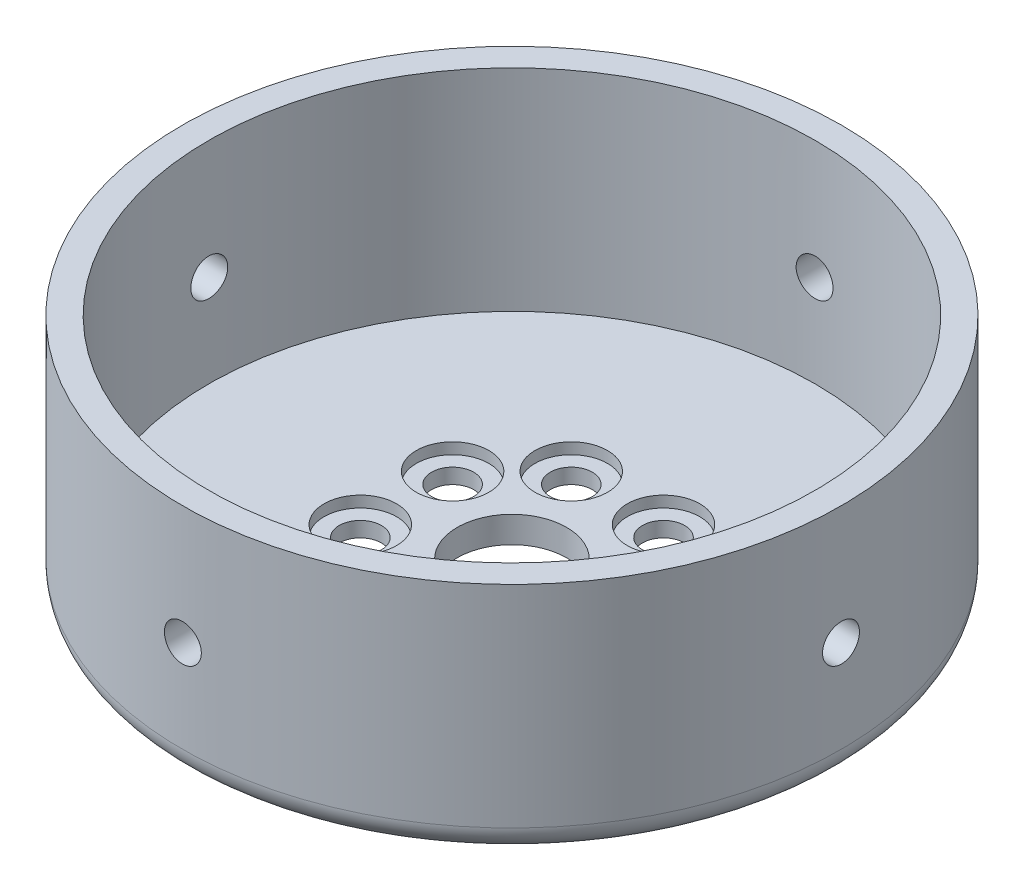
from build123d import *

# Parameters (mm, degrees)
SKETCH2_R          = 4.15
CUT_EXTRUDE1_DEPTH = 10
SKETCH3_R          = 1.4
CUT_EXTRUDE3_DEPTH = 30
CIRPATTERN1_COUNT  = 4
FILLET1_R          = 2
SKETCH4_R          = 1.6
CUT_EXTRUDE4_DEPTH = 19.0000001
SKETCH6_R          = 2.75
CUT_EXTRUDE5_DEPTH = 0.85


with BuildPart() as part:
    # Sketch1 → Revolve1 (revolve)
    with BuildSketch(Plane.XY):
        Polygon((0, 0), (0, 2), (23, 2), (23, 18), (25, 18), (25, 0), align=None)
    revolve(axis=Axis((0, 0, 0), (0, 1, 0)))

    # Sketch2 → Cut-Extrude1 (cut)
    with BuildSketch(Plane(origin=(0, 2, 0), x_dir=(1, 0, 0), z_dir=(0, 1, 0))):
        Circle(SKETCH2_R)
    extrude(amount=-CUT_EXTRUDE1_DEPTH, mode=Mode.SUBTRACT)

    # Sketch3 → Cut-Extrude3 (cut, symmetric)
    with BuildSketch(Plane.XY):
        with Locations((0, 9)):
            Circle(SKETCH3_R)
    cut_extrude3 = extrude(amount=CUT_EXTRUDE3_DEPTH, both=True, mode=Mode.SUBTRACT)

    # CirPattern1: Cut-Extrude3 ×4 about axis
    cirpattern1_axis = Axis((0, 0, 0), (0, -1, 0))
    for i in range(1, CIRPATTERN1_COUNT):
        add(cut_extrude3.rotate(cirpattern1_axis, i * 360 / CIRPATTERN1_COUNT), mode=Mode.SUBTRACT)

    # Fillet1
    fillet1_edges = [part.edges().sort_by_distance(p)[0] for p in [
        (-25, 0, 0),
    ]]
    fillet(fillet1_edges, radius=FILLET1_R)

    # Sketch4 → Cut-Extrude4 (cut, through all)
    with BuildSketch(Plane.XZ):
        with Locations((-3.5, 8)):
            Circle(SKETCH4_R)
        with Locations((3.5, 8)):
            Circle(SKETCH4_R)
        with Locations((-8, 3.5)):
            Circle(SKETCH4_R)
        with Locations((8, 3.5)):
            Circle(SKETCH4_R)
    cut_extrude4 = extrude(amount=-CUT_EXTRUDE4_DEPTH, mode=Mode.SUBTRACT)

    # Sketch6 → Cut-Extrude5 (cut)
    with BuildSketch(Plane(origin=(0, 2, 0), x_dir=(1, 0, 0), z_dir=(0, 1, 0))):
        with Locations((-8, -3.5)):
            Circle(SKETCH6_R)
        with Locations((-3.5, -8)):
            Circle(SKETCH6_R)
        with Locations((3.5, -8)):
            Circle(SKETCH6_R)
        with Locations((8, -3.5)):
            Circle(SKETCH6_R)
    cut_extrude5 = extrude(amount=-CUT_EXTRUDE5_DEPTH, mode=Mode.SUBTRACT)

    # Mirror1: Cut-Extrude4, Cut-Extrude5 across plane
    add(cut_extrude4.mirror(Plane.XY), mode=Mode.SUBTRACT)
    add(cut_extrude5.mirror(Plane.XY), mode=Mode.SUBTRACT)


solid = part.part
